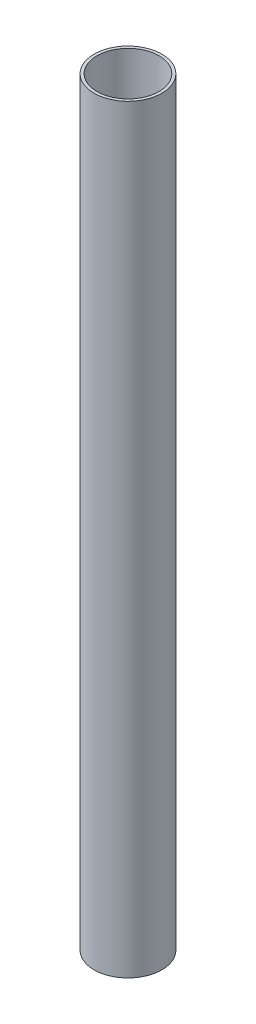
from build123d import *

# Parameters (mm, degrees)
SKETCH1_R           = 14.732
BOSS_EXTRUDE1_DEPTH = 330.2
SKETCH2_R           = 13.494366606
CUT_EXTRUDE1_DEPTH  = 330.2


with BuildPart() as part:
    # Sketch1 → Boss-Extrude1 (new body)
    with BuildSketch(Plane(origin=(0, 0, 0), x_dir=(1, 0, 0), z_dir=(0, 1, 0))):
        Circle(SKETCH1_R)
    extrude(amount=BOSS_EXTRUDE1_DEPTH)

    # Sketch2 → Cut-Extrude1 (cut)
    with BuildSketch(Plane(origin=(0, 330.2, 0), x_dir=(1, 0, 0), z_dir=(0, 1, 0))):
        Circle(SKETCH2_R)
    extrude(amount=-CUT_EXTRUDE1_DEPTH, mode=Mode.SUBTRACT)


solid = part.part
